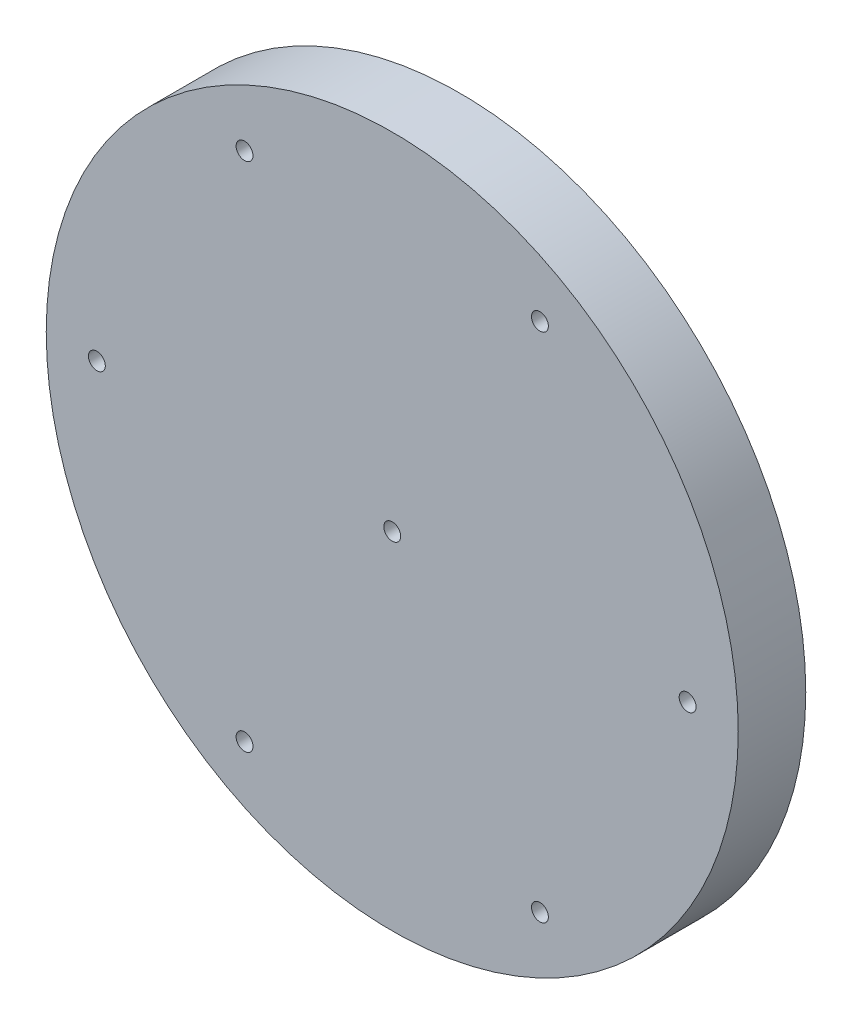
from build123d import *

# Parameters (mm, degrees)
MODEL_R             = 20.5
MODEL_R_2           = 0.5
BOSS_EXTRUDE1_DEPTH = 4


with BuildPart() as part:
    # Model → Boss-Extrude1 (new body)
    with BuildSketch(Plane.XY):
        Circle(MODEL_R)
        Circle(MODEL_R_2, mode=Mode.SUBTRACT)
        with Locations((17.5, 0)):
            Circle(MODEL_R_2, mode=Mode.SUBTRACT)
        with Locations((8.75, 15.155444566)):
            Circle(MODEL_R_2, mode=Mode.SUBTRACT)
        with Locations((-8.75, 15.155444566)):
            Circle(MODEL_R_2, mode=Mode.SUBTRACT)
        with Locations((-17.5, 0)):
            Circle(MODEL_R_2, mode=Mode.SUBTRACT)
        with Locations((-8.75, -15.155444566)):
            Circle(MODEL_R_2, mode=Mode.SUBTRACT)
        with Locations((8.75, -15.155444566)):
            Circle(MODEL_R_2, mode=Mode.SUBTRACT)
    extrude(amount=BOSS_EXTRUDE1_DEPTH)


solid = part.part
